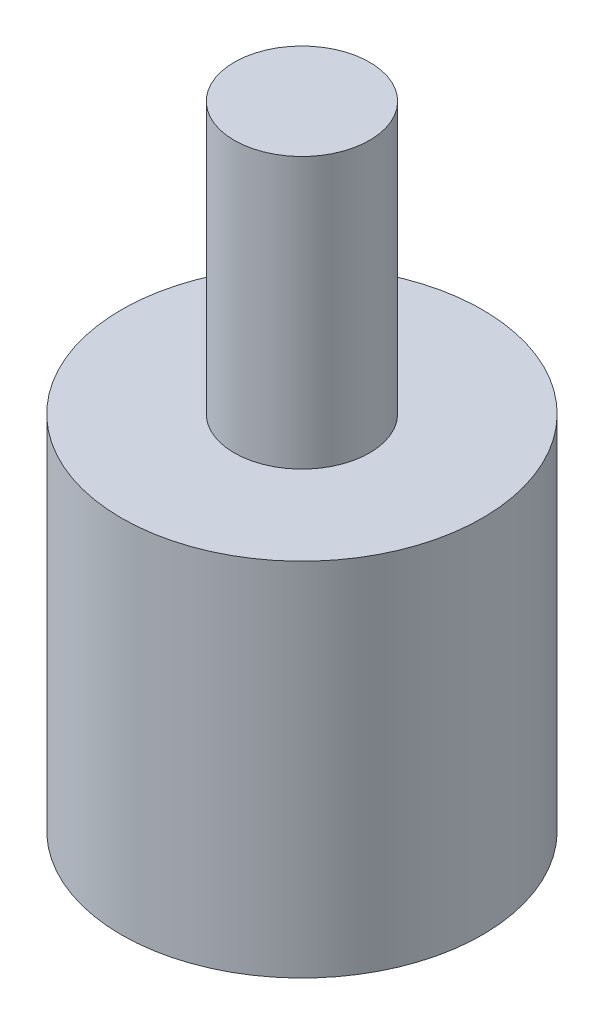
from build123d import *

# Parameters (mm, degrees)
SKETCH1_R           = 4
BOSS_EXTRUDE1_DEPTH = 8
SKETCH2_R           = 1.5
BOSS_EXTRUDE2_DEPTH = 6


with BuildPart() as part:
    # Sketch1 → Boss-Extrude1 (new body)
    with BuildSketch(Plane(origin=(0, 0, 0), x_dir=(1, 0, 0), z_dir=(0, 1, 0))):
        Circle(SKETCH1_R)
    extrude(amount=BOSS_EXTRUDE1_DEPTH)

    # Sketch2 → Boss-Extrude2 (add)
    with BuildSketch(Plane(origin=(0, 8, 0), x_dir=(1, 0, 0), z_dir=(0, 1, 0))):
        Circle(SKETCH2_R)
    extrude(amount=BOSS_EXTRUDE2_DEPTH)


solid = part.part
